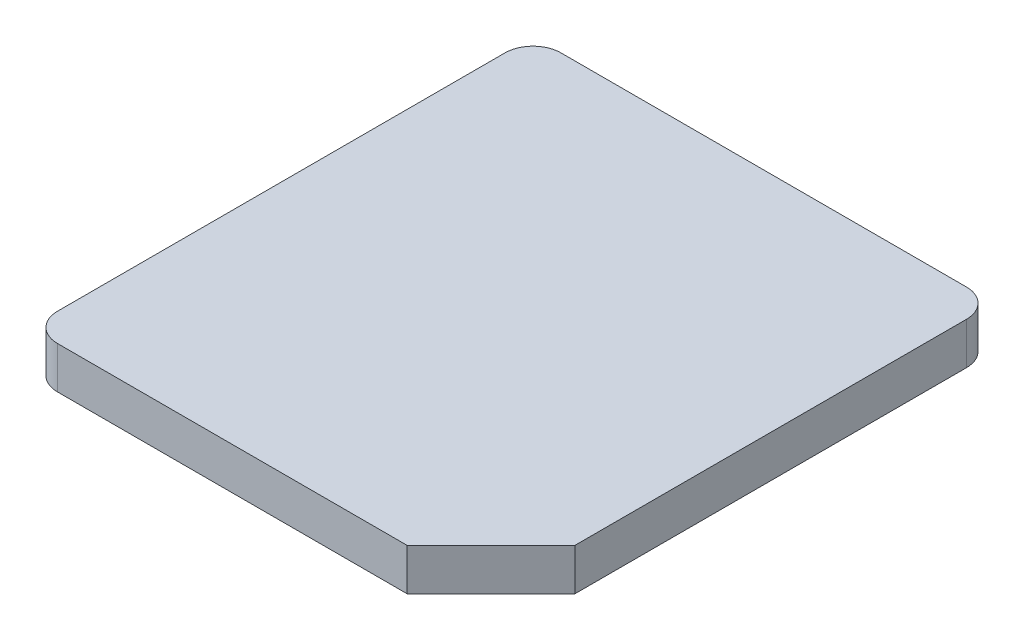
from build123d import *

# Parameters (mm, degrees)
SKETCH1_W           = 1.65
SKETCH1_H           = 1.8
BOSS_EXTRUDE1_DEPTH = 0.15
CUT_EXTRUDE1_DEPTH  = 1.15
FILLET1_R           = 0.1


with BuildPart() as part:
    # Sketch1 → Boss-Extrude1 (new body)
    with BuildSketch(Plane(origin=(0, 0, 0), x_dir=(1, 0, 0), z_dir=(0, 1, 0))):
        Rectangle(SKETCH1_W, SKETCH1_H)
    extrude(amount=BOSS_EXTRUDE1_DEPTH)

    # Sketch2 → Cut-Extrude1 (cut, through all)
    with BuildSketch(Plane(origin=(0, 0.15, 0), x_dir=(1, 0, 0), z_dir=(0, 1, 0))):
        Polygon((0.525, -0.9), (0.825, -0.6), (0.825, -0.9), align=None)
    extrude(amount=-CUT_EXTRUDE1_DEPTH, mode=Mode.SUBTRACT)

    # Fillet1
    fillet1_edges = [part.edges().sort_by_distance(p)[0] for p in [
        (-0.825, 0.075, 0.9),
        (-0.825, 0.075, -0.9),
        (0.825, 0.075, -0.9),
    ]]
    fillet(fillet1_edges, radius=FILLET1_R)


solid = part.part
